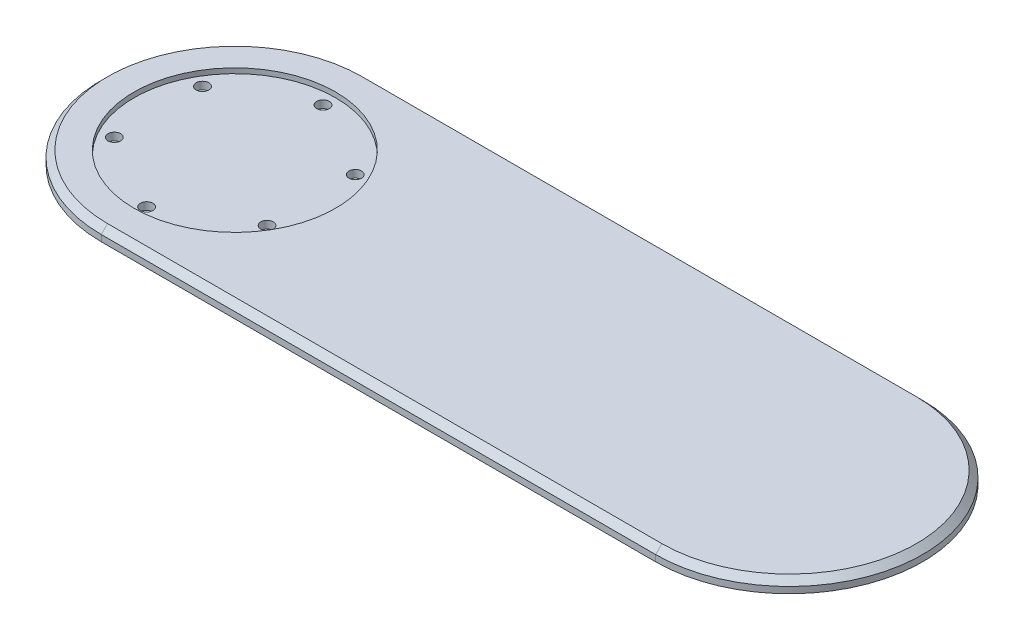
from build123d import *

# Parameters (mm, degrees)
SKETCH1_R           = 2.5
BOSS_EXTRUDE1_DEPTH = 5
SKETCH2_R           = 40
CUT_EXTRUDE1_DEPTH  = 2
CHAMFER1_SIZE       = 2.5


with BuildPart() as part:
    # Sketch1 → Boss-Extrude1 (new body)
    with BuildSketch(Plane(origin=(0, 0, 0), x_dir=(1, 0, 0), z_dir=(0, 1, 0))):
        with BuildLine():
            Line((-110, -53), (110, -53))
            ThreePointArc((110, -53), (163, 0), (110, 53))
            Line((110, 53), (-110, 53))
            ThreePointArc((-110, 53), (-163, 0), (-110, -53))
        make_face()
        with Locations((-110, -35)):
            Circle(SKETCH1_R, mode=Mode.SUBTRACT)
        with Locations((-110, 35)):
            Circle(SKETCH1_R, mode=Mode.SUBTRACT)
        with Locations((-79.689110868, 17.5)):
            Circle(SKETCH1_R, mode=Mode.SUBTRACT)
        with Locations((-79.689110868, -17.5)):
            Circle(SKETCH1_R, mode=Mode.SUBTRACT)
        with Locations((-140.310889132, 17.5)):
            Circle(SKETCH1_R, mode=Mode.SUBTRACT)
        with Locations((-140.310889132, -17.5)):
            Circle(SKETCH1_R, mode=Mode.SUBTRACT)
    extrude(amount=BOSS_EXTRUDE1_DEPTH)

    # Sketch2 → Cut-Extrude1 (cut)
    with BuildSketch(Plane(origin=(0, 5, 0), x_dir=(1, 0, 0), z_dir=(0, 1, 0))):
        with Locations((-110, 0)):
            Circle(SKETCH2_R)
    extrude(amount=-CUT_EXTRUDE1_DEPTH, mode=Mode.SUBTRACT)

    # Chamfer1
    chamfer1_edges = [part.edges().sort_by_distance(p)[0] for p in [
        (-163, 5, 0),
        (0, 5, 53),
        (163, 5, 0),
        (0, 5, -53),
    ]]
    chamfer(chamfer1_edges, length=CHAMFER1_SIZE)


solid = part.part
